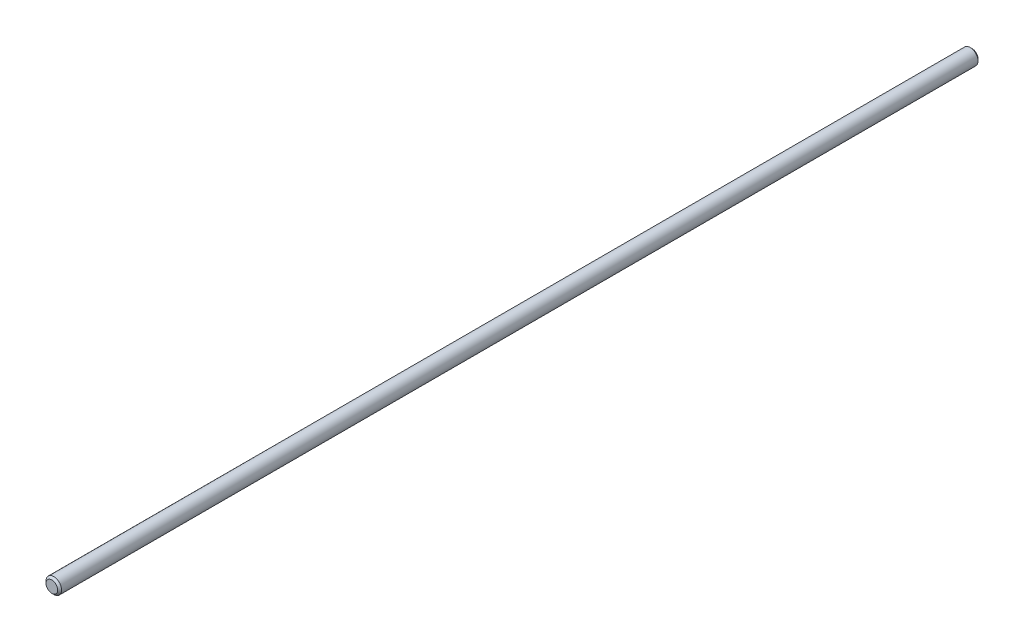
from build123d import *

# Parameters (mm, degrees)
SKETCH1_R           = 3.975
BOSS_EXTRUDE1_DEPTH = 470
CHAMFER1_SIZE       = 1


with BuildPart() as part:
    # Sketch1 → Boss-Extrude1 (new body)
    with BuildSketch(Plane.XY):
        Circle(SKETCH1_R)
    extrude(amount=BOSS_EXTRUDE1_DEPTH)

    # Chamfer1
    chamfer1_edges = [part.edges().sort_by_distance(p)[0] for p in [
        (-3.975, 0, 0),
        (-3.975, 0, 470),
    ]]
    chamfer(chamfer1_edges, length=CHAMFER1_SIZE)


solid = part.part
